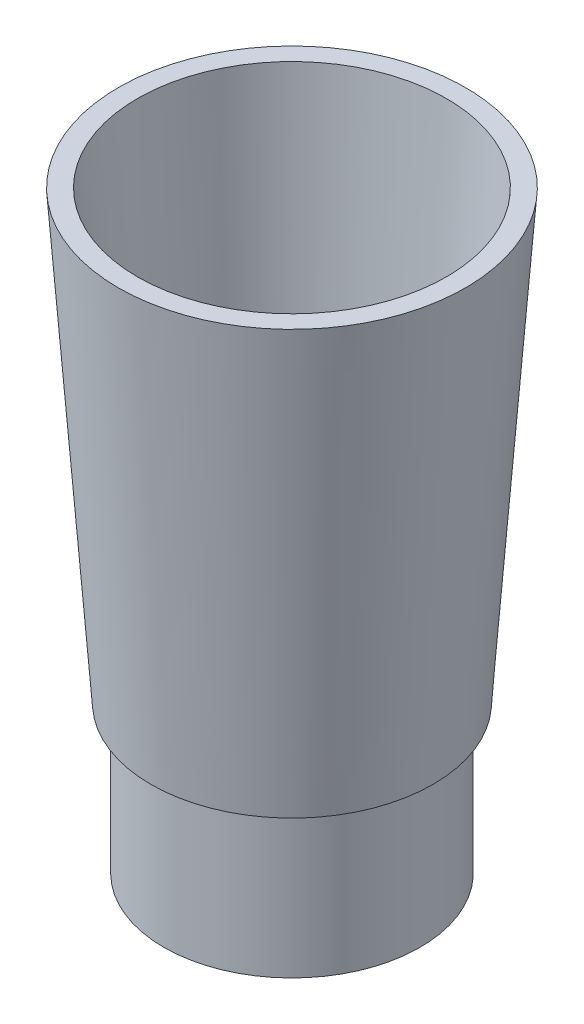
from build123d import *


with BuildPart() as part:
    # Sketch1 → Revolve1 (revolve)
    with BuildSketch(Plane.XY, mode=Mode.PRIVATE) as revolve1_sk:
        Polygon((11.5, 0), (11.5, 17.544649407), (13, 17.544649407), (16.273009701, 62.544649407), (18.278292892, 62.544649407), (14.859816093, 15.544649407), (13.5, 15.544649407), (13.5, 0), align=None)
    revolve(revolve1_sk.sketch.rotate(Axis((0, 70.073472281, 0), (0, -1, 0)), 90), axis=Axis((0, 70.073472281, 0), (0, -1, 0)))  # turned: the seam where the file's is


solid = part.part
